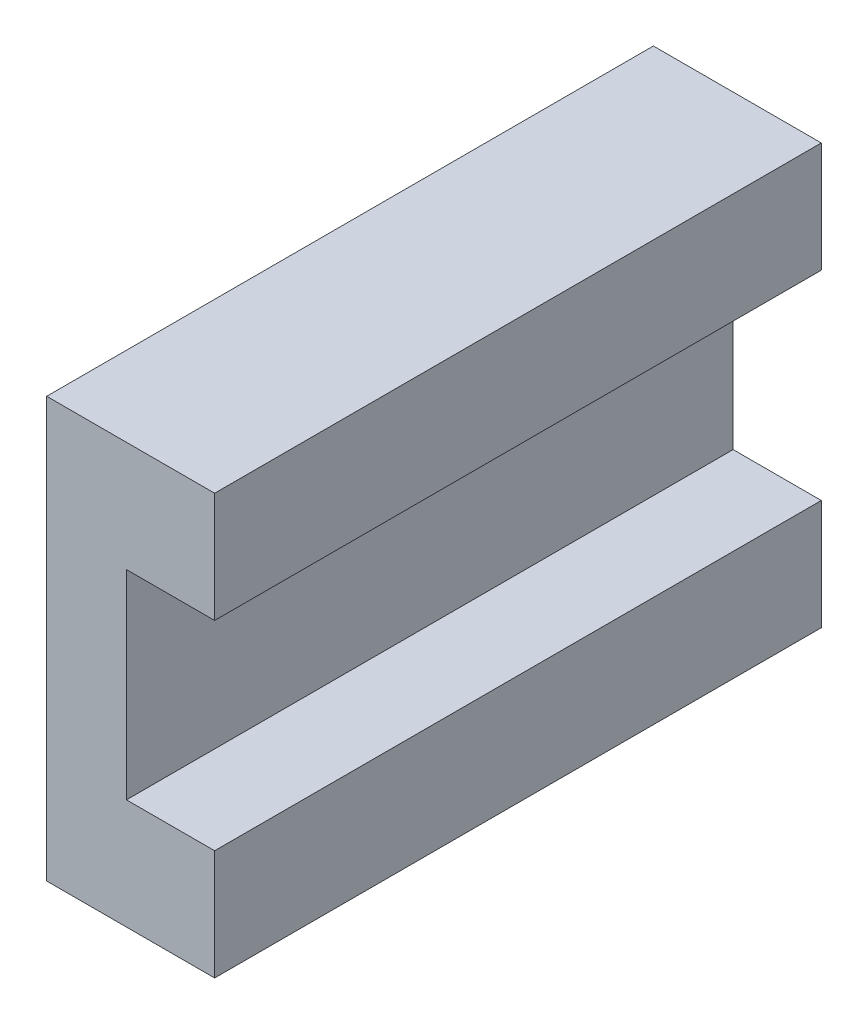
from build123d import *

# Parameters (mm, degrees)
SKETCH1_W                      = 6.5
SKETCH1_H                      = 9
BOSS_EXTRUDE1_DEPTH            = 150
BOSS_EXTRUDE2_DEPTH            = 14.45
M3X0_5_TAPPED_HOLE1_AT_2_COUNT = 2
M3X0_5_TAPPED_HOLE1_AT_2_PITCH = 18.027756377
M3X0_5_TAPPED_HOLE1_AT_3_COUNT = 2
M3X0_5_TAPPED_HOLE1_AT_3_PITCH = 15
M3X0_5_TAPPED_HOLE1_AT_4_COUNT = 2
M3X0_5_TAPPED_HOLE1_AT_4_PITCH = 10
LPATTERN1_COUNT                = 15
LPATTERN1_PITCH                = 20


with BuildPart() as part:
    # Sketch1 → Boss-Extrude1 (new body, symmetric)
    with BuildSketch(Plane.XY):
        Rectangle(SKETCH1_W, SKETCH1_H)
    extrude(amount=BOSS_EXTRUDE1_DEPTH, both=True)

    # Sketch6 → CBORE for M3 SHCS1 (revolve, cut)
    with BuildSketch(Plane(origin=(-3.25, 0, -140), x_dir=(0, 0, 1), z_dir=(0, 1, 0))):
        Polygon((0, 0), (0, 6.5), (1.8, 6.5), (1.8, 3), (3.25, 3), (3.25, 0), align=None)
    cbore_for_m3_shcs1 = revolve(axis=Axis((-9.6, 0, -140), (1, 0, 0)), mode=Mode.SUBTRACT)

    # LPattern1: CBORE for M3 SHCS1 ×15
    with Locations(*[(0, 0, i * LPATTERN1_PITCH) for i in range(1, LPATTERN1_COUNT)]):
        add(cbore_for_m3_shcs1, mode=Mode.SUBTRACT)


with BuildPart() as body_2:
    # Sketch2 → Boss-Extrude2 (new body, symmetric)
    with BuildSketch(Plane.XY):
        Polygon((0.75, 4.75), (0.75, 10), (-7.25, 10), (-7.25, -10), (0.75, -10), (0.75, -4.75), (-3.45, -4.75), (-3.45, 4.75), align=None)
    extrude(amount=BOSS_EXTRUDE2_DEPTH, both=True)

    # Sketch4 → M3x0.5 Tapped Hole1 (revolve, cut)
    with BuildSketch(Plane(origin=(-7.25, 7.5, -5), x_dir=(0, 0, 1), z_dir=(0, 1, 0))):
        Polygon((0, 0), (0, 3.751075774), (1.25, 3), (1.25, 0), align=None)
    m3x0_5_tapped_hole1 = revolve(axis=Axis((-13.6, 7.5, -5), (1, 0, 0)), mode=Mode.SUBTRACT)

    # M3x0.5 Tapped Hole1 at 2: M3x0.5 Tapped Hole1 ×2
    with Locations(*[Vector(0, -0.832050294, 0.554700196) * (i * M3X0_5_TAPPED_HOLE1_AT_2_PITCH) for i in range(1, M3X0_5_TAPPED_HOLE1_AT_2_COUNT)]):
        add(m3x0_5_tapped_hole1, mode=Mode.SUBTRACT)

    # M3x0.5 Tapped Hole1 at 3: M3x0.5 Tapped Hole1 ×2
    with Locations(*[(0, -i * M3X0_5_TAPPED_HOLE1_AT_3_PITCH, 0) for i in range(1, M3X0_5_TAPPED_HOLE1_AT_3_COUNT)]):
        add(m3x0_5_tapped_hole1, mode=Mode.SUBTRACT)

    # M3x0.5 Tapped Hole1 at 4: M3x0.5 Tapped Hole1 ×2
    with Locations(*[(0, 0, i * M3X0_5_TAPPED_HOLE1_AT_4_PITCH) for i in range(1, M3X0_5_TAPPED_HOLE1_AT_4_COUNT)]):
        add(m3x0_5_tapped_hole1, mode=Mode.SUBTRACT)


with BuildPart() as body_2_1:
    # Body-Move/Copy1: moved
    add(body_2.part.moved(Location((0, 0, 5))))


solid = body_2_1.part
